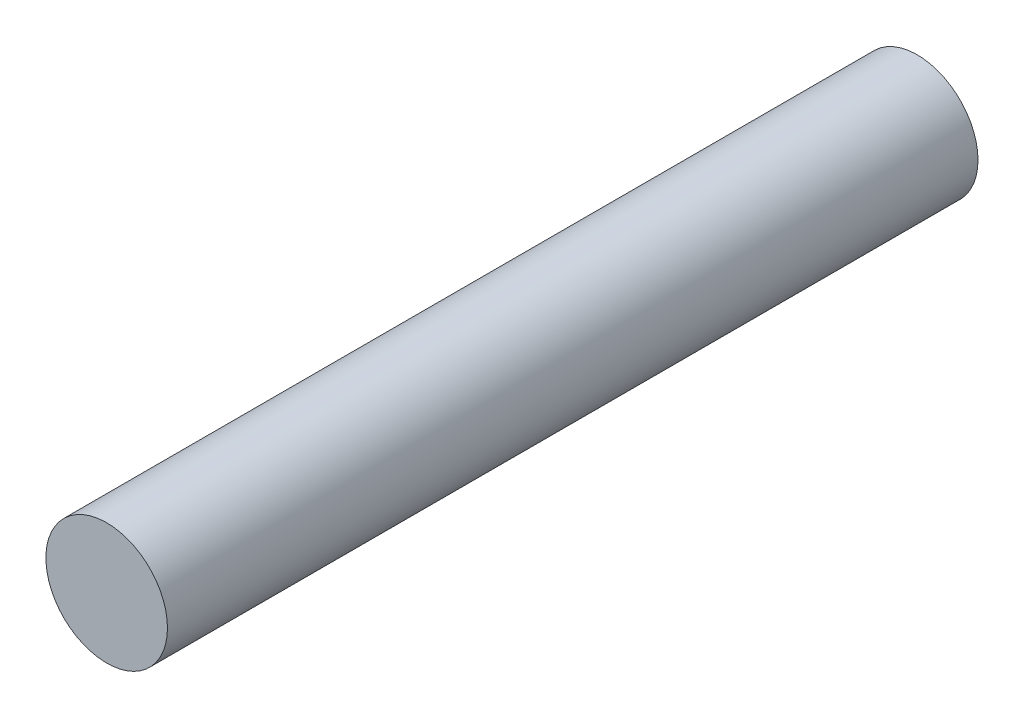
from build123d import *

# Parameters (mm, degrees)
SKETCH_1_R      = 1.5
EXTRUDE_1_DEPTH = 20


with BuildPart() as part:
    # 草图1 → 凸台-拉伸1 (new body)
    with BuildSketch(Plane.XY):
        Circle(SKETCH_1_R)
    extrude(amount=EXTRUDE_1_DEPTH)


solid = part.part
